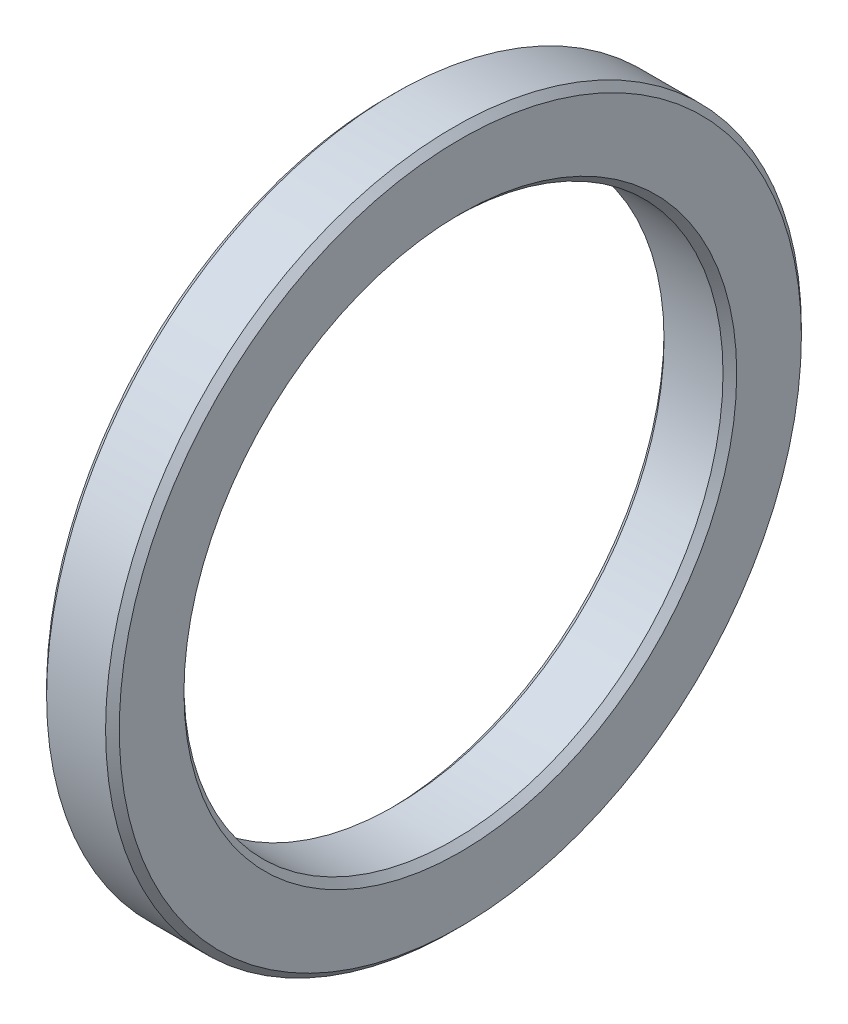
from build123d import *

# Parameters (mm, degrees)
SKETCH1_R           = 32.27
SKETCH1_R_2         = 25
BOSS_EXTRUDE1_DEPTH = 6.74
CHAMFER1_SIZE       = 0.635
CHAMFER2_SIZE       = 0.635


with BuildPart() as part:
    # Sketch1 → Boss-Extrude1 (new body)
    with BuildSketch(Plane(origin=(0, 0, 0), x_dir=(0, 0, -1), z_dir=(1, 0, 0))):
        Circle(SKETCH1_R)
        Circle(SKETCH1_R_2, mode=Mode.SUBTRACT)
    extrude(amount=BOSS_EXTRUDE1_DEPTH)

    # Chamfer1
    chamfer1_edges = [part.edges().sort_by_distance(p)[0] for p in [
        (0, 0, 32.27),
        (6.74, 0, 32.27),
    ]]
    chamfer(chamfer1_edges, length=CHAMFER1_SIZE)

    # Chamfer2
    chamfer2_edges = [part.edges().sort_by_distance(p)[0] for p in [
        (0, 0, 25),
        (6.74, 0, 25),
    ]]
    chamfer(chamfer2_edges, length=CHAMFER2_SIZE)


solid = part.part
